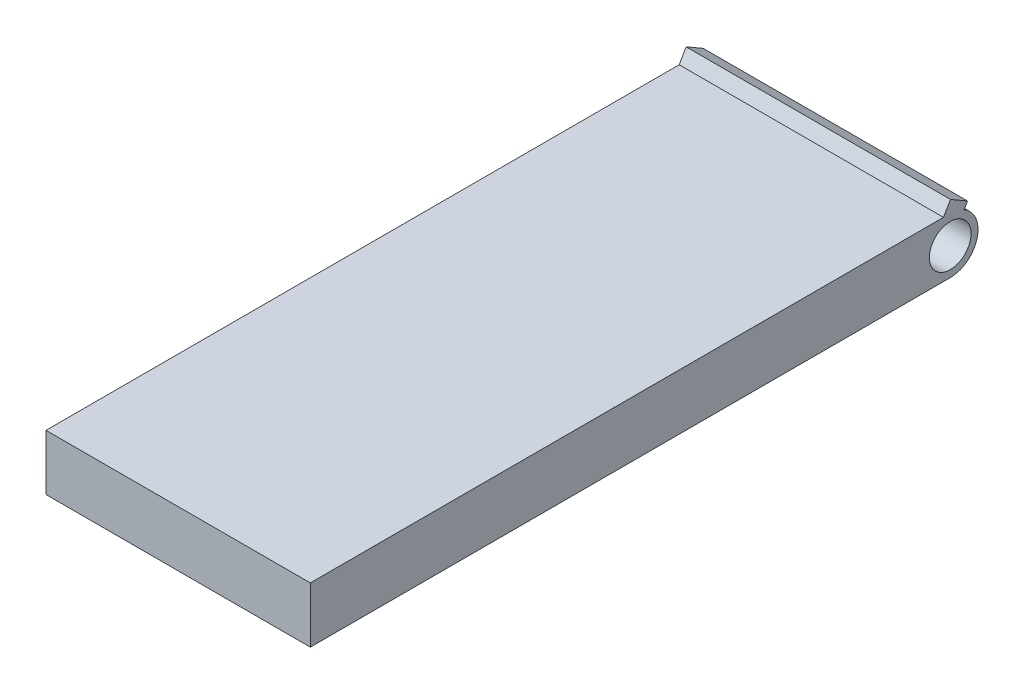
from build123d import *

# Parameters (mm, degrees)
SKETCH_1_W          = 9.5
SKETCH_1_H          = 24
EXTRUDE_1_DEPTH     = 2
SKETCH_5_R          = 0.75
CUT_EXTRUDE_4_DEPTH = 10.5
EXTRUDE_2_DEPTH     = 9.5


with BuildPart() as part:
    # 草图1 → 凸台-拉伸1 (new body)
    with BuildSketch(Plane(origin=(0, 0, 0), x_dir=(1, 0, 0), z_dir=(0, 1, 0))):
        with Locations((0, 0.261859188)):
            Rectangle(SKETCH_1_W, SKETCH_1_H)
    extrude(amount=EXTRUDE_1_DEPTH)

    # 草图5 → 切除-拉伸4 (cut, through all)
    with BuildSketch(Plane(origin=(4.75, 0, 0), x_dir=(0, 0, -1), z_dir=(1, 0, 0))):
        with BuildLine():
            Line((12.261859188, 0), (12.261859188, 1))
            ThreePointArc((12.261859188, 1), (11.968965969, 0.292893219), (11.261859188, 0))
            Line((11.261859188, 0), (12.261859188, 0))
        make_face()
        with BuildLine():
            Line((11.839209457, 2), (11.761859188, 1.866025404))
            ThreePointArc((11.761859188, 1.866025404), (12.127884592, 1.5), (12.261859188, 1))
            Line((12.261859188, 1), (12.261859188, 2))
            Line((12.261859188, 2), (11.839209457, 2))
        make_face()
        with Locations((11.261859188, 1)):
            Circle(SKETCH_5_R)
    extrude(amount=-CUT_EXTRUDE_4_DEPTH, mode=Mode.SUBTRACT)

    # 草图5<4> → 凸台-拉伸2 (add)
    with BuildSketch(Plane(origin=(4.75, 0, 0), x_dir=(0, 0, -1), z_dir=(1, 0, 0))):
        Polygon((11.261859188, 2), (11.839209457, 2), (11.884340006, 2.078168404), (11.269731653, 2.433012702), (11.019731653, 2), align=None)
    extrude(amount=-EXTRUDE_2_DEPTH)


solid = part.part
